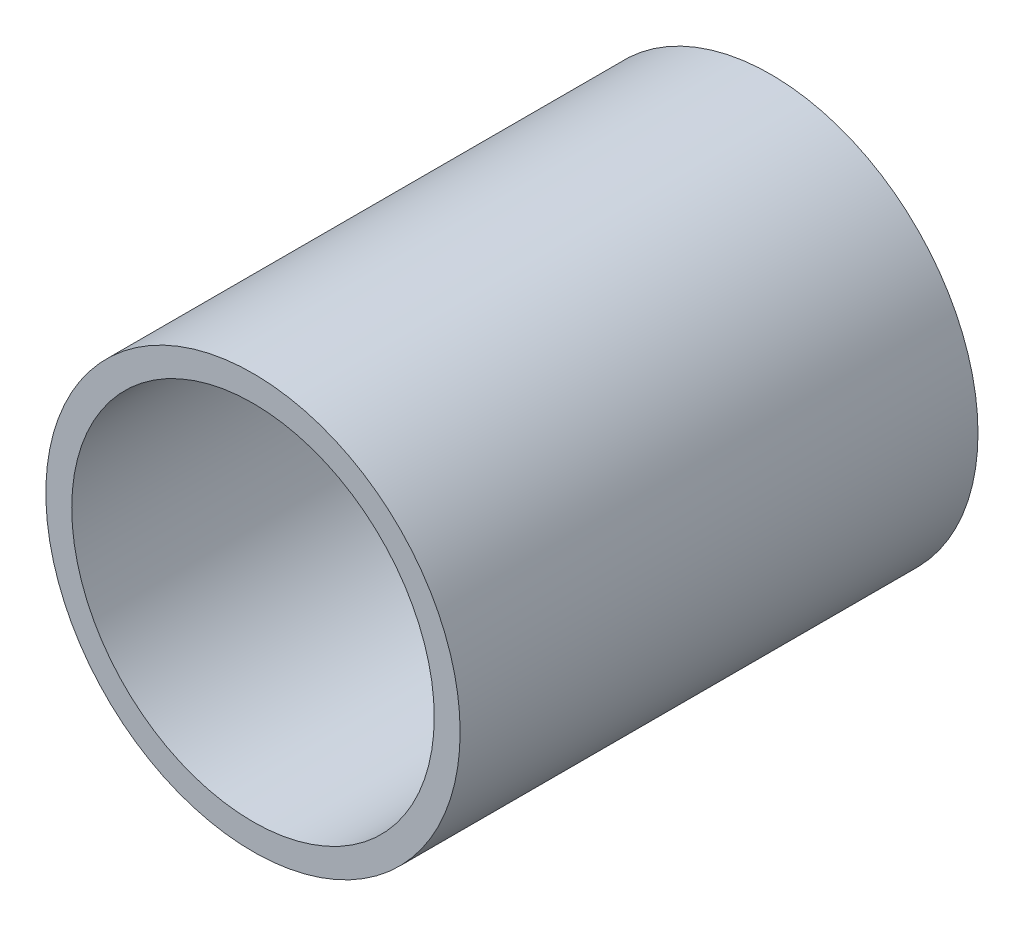
from build123d import *

# Parameters (mm, degrees)
ESQUISSE1_R          = 4
ESQUISSE1_R_2        = 3.5
BASE_EXTRUSION_DEPTH = 10


with BuildPart() as part:
    # Esquisse1 → Base-Extrusion (new body)
    with BuildSketch(Plane.XY):
        Circle(ESQUISSE1_R)
        Circle(ESQUISSE1_R_2, mode=Mode.SUBTRACT)
    extrude(amount=BASE_EXTRUSION_DEPTH)


solid = part.part
